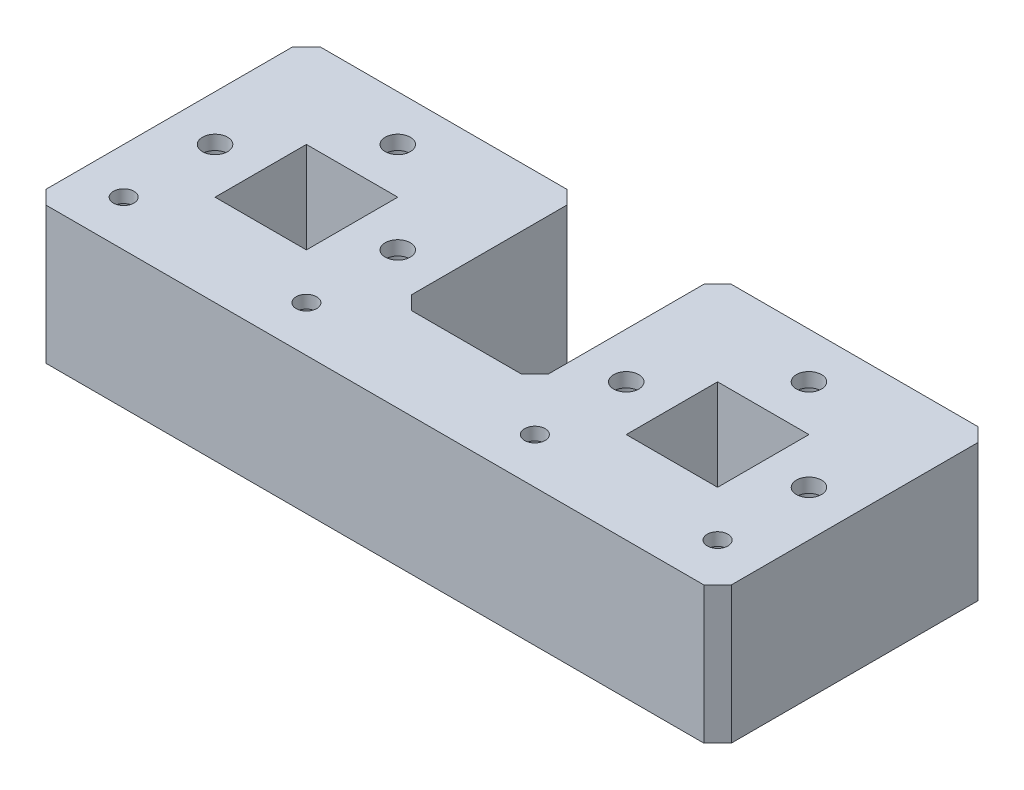
from build123d import *

# Parameters (mm, degrees)
SKIZZE1_W                                            = 20
SKIZZE1_H                                            = 20
AUFSATZ_LINEAR_AUSTRAGEN1_DEPTH                      = 30
STIRNSENKUNG_F_R_M5_ZYLINDERSCHRAUBE_MIT_D           = 5.5
STIRNSENKUNG_F_R_M5_ZYLINDERSCHRAUBE_MIT_CBORE_D     = 10
STIRNSENKUNG_F_R_M5_ZYLINDERSCHRAUBE_MIT_CBORE_DEPTH = 26.9
STIRNSENKUNG_F_R_M4_ZYLINDERSCHRAUBE_MIT_D           = 4.5
STIRNSENKUNG_F_R_M4_ZYLINDERSCHRAUBE_MIT_CBORE_D     = 8
STIRNSENKUNG_F_R_M4_ZYLINDERSCHRAUBE_MIT_CBORE_DEPTH = 27.2
FASE1_SIZE                                           = 3
FASE1_OF_SPIEGELN2_SIZE                              = 3


with BuildPart() as part:
    # Skizze1 → Aufsatz-Linear austragen1 (new body)
    with BuildSketch(Plane(origin=(0, 0, 0), x_dir=(1, 0, 0), z_dir=(0, 1, 0))):
        Polygon((0, -10), (0, -30), (-75, -30), (-75, 30), (-15, 30), (-15, -10), align=None)
        with Locations((-45, 0)):
            Rectangle(SKIZZE1_W, SKIZZE1_H, mode=Mode.SUBTRACT)
    aufsatz_linear_austragen1 = extrude(amount=AUFSATZ_LINEAR_AUSTRAGEN1_DEPTH)

    # Stirnsenkung für M5 Zylinderschraube mit Innensechskant1 (through all)
    with Locations(Plane(origin=(0, 0, 0), x_dir=(-1, 0, 0), z_dir=(0, -1, 0))):
        with Locations((45, 20), (25, 0), (65, 0)):
            stirnsenkung_f_r_m5_zylinderschraube_mit = CounterBoreHole(STIRNSENKUNG_F_R_M5_ZYLINDERSCHRAUBE_MIT_D / 2, STIRNSENKUNG_F_R_M5_ZYLINDERSCHRAUBE_MIT_CBORE_D / 2, STIRNSENKUNG_F_R_M5_ZYLINDERSCHRAUBE_MIT_CBORE_DEPTH)

    # Stirnsenkung für M4 Zylinderschraube mit Innensechskant1 (through all)
    with Locations(Plane(origin=(0, 0, 0), x_dir=(-1, 0, 0), z_dir=(0, -1, 0))):
        with Locations((25, -20), (65, -20)):
            stirnsenkung_f_r_m4_zylinderschraube_mit = CounterBoreHole(STIRNSENKUNG_F_R_M4_ZYLINDERSCHRAUBE_MIT_D / 2, STIRNSENKUNG_F_R_M4_ZYLINDERSCHRAUBE_MIT_CBORE_D / 2, STIRNSENKUNG_F_R_M4_ZYLINDERSCHRAUBE_MIT_CBORE_DEPTH)

    # Fase1
    fase1_edges = [part.edges().sort_by_distance(p)[0] for p in [
        (-75, 15, -30),
        (-15, 15, -30),
        (-15, 15, 10),
        (-75, 15, 30),
    ]]
    chamfer(fase1_edges, length=FASE1_SIZE)

    # Spiegeln2: Aufsatz-Linear austragen1, Stirnsenkung für M5 Zylinderschraube mit Innensechskant1, Stirnsenkung für M4 Zylinderschraube mit Innensechskant1 across plane
    add(aufsatz_linear_austragen1.mirror(Plane(origin=(0, 0, 0), x_dir=(0, 0, 1), z_dir=(1, 0, 0))))
    add(stirnsenkung_f_r_m5_zylinderschraube_mit.mirror(Plane(origin=(0, 0, 0), x_dir=(0, 0, 1), z_dir=(1, 0, 0))), mode=Mode.SUBTRACT)
    add(stirnsenkung_f_r_m4_zylinderschraube_mit.mirror(Plane(origin=(0, 0, 0), x_dir=(0, 0, 1), z_dir=(1, 0, 0))), mode=Mode.SUBTRACT)

    # Fase1 of Spiegeln2
    fase1_of_spiegeln2_edges = [part.edges().sort_by_distance(p)[0] for p in [
        (75, 15, -30),
        (15, 15, -30),
        (15, 15, 10),
        (75, 15, 30),
    ]]
    chamfer(fase1_of_spiegeln2_edges, length=FASE1_OF_SPIEGELN2_SIZE)


solid = part.part
